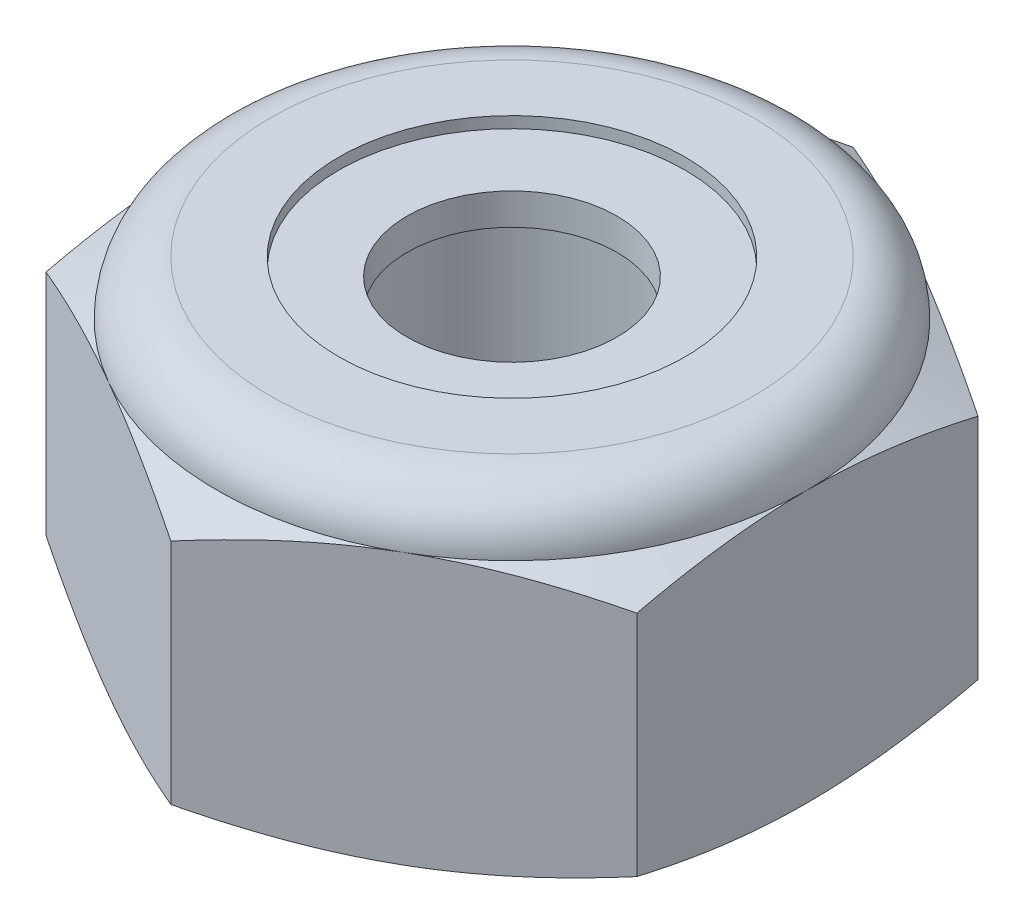
from build123d import *

# Parameters (mm, degrees)
EXTRUDE1_DEPTH = 4.365625
SKETCH2_W      = 1.7526
SKETCH2_H      = 4.365625


with BuildPart() as part:
    # Sketch1 → Extrude1 (new body)
    with BuildSketch(Plane(origin=(0, 0, 0), x_dir=(1, 0, 0), z_dir=(0, 1, 0))):
        Polygon((0, 4.582717762), (-3.96875, 2.291358881), (-3.96875, -2.291358881), (0, -4.582717762), (3.96875, -2.291358881), (3.96875, 2.291358881), align=None)
    extrude(amount=EXTRUDE1_DEPTH)

    # Sketch4 → Cut-Revolve2 (revolve, cut)
    with BuildSketch(Plane(origin=(0, 0, 0), x_dir=(0, 0, -1), z_dir=(1, 0, 0))):
        Polygon((0, 4.365625), (1.7526, 4.365625), (1.410275607, 4.205996514), (1.410275607, 0.159628486), (1.7526, 0), (0, 0), align=None)
    revolve(axis=Axis((0, 4.365625, 0), (0, 1, 0)), mode=Mode.SUBTRACT)


with BuildPart() as body_2:
    # Sketch2 → Revolve1 (revolve)
    with BuildSketch(Plane(origin=(0, 0, 0), x_dir=(0, 0, -1), z_dir=(1, 0, 0))):
        with Locations((0.8763, 2.1828125)):
            Rectangle(SKETCH2_W, SKETCH2_H)
    revolve(axis=Axis((0, -1.7526, 0), (0, 1, 0)))


with BuildPart() as part_1:
    add(part.part)

    # Combine1: cut body 2
    add(body_2.part, mode=Mode.SUBTRACT)

    # Sketch5 → Cut-Revolve3 (revolve, cut)
    with BuildSketch(Plane(origin=(0, 0, 0), x_dir=(0, 0, -1), z_dir=(1, 0, 0))):
        with BuildLine():
            Line((0, 0), (3.96875, 0))
            Line((3.96875, 0), (4.582717762, 0.286297869))
            Line((4.582717762, 0.286297869), (4.582717762, 3.351722964))
            Line((4.582717762, 3.351722964), (3.96875, 3.638020833))
            ThreePointArc((3.96875, 3.638020833), (3.755639674, 4.152514674), (3.241145833, 4.365625))
            Line((3.241145833, 4.365625), (3.241145833, 5.635625))
            Line((3.241145833, 5.635625), (5.852717762, 5.635625))
            Line((5.852717762, 5.635625), (5.852717762, -1.27))
            Line((5.852717762, -1.27), (0, -1.27))
            Line((0, -1.27), (0, 0))
        make_face()
    revolve(axis=Axis((0, 0, 0), (0, 1, 0)), mode=Mode.SUBTRACT)

    # Sketch6 → Cut-Revolve4 (revolve, cut)
    with BuildSketch(Plane(origin=(0, 0, 0), x_dir=(0, 0, -1), z_dir=(1, 0, 0))):
        with BuildLine():
            Line((0, 3.638020833), (3.81635, 3.638020833))
            ThreePointArc((3.81635, 3.638020833), (3.6478766, 4.0447516), (3.241145833, 4.213225))
            Line((3.241145833, 4.213225), (2.32571072, 4.213225))
            Line((2.32571072, 4.213225), (2.32571072, 5.635625))
            Line((2.32571072, 5.635625), (0, 5.635625))
            Line((0, 5.635625), (0, 3.638020833))
        make_face()
    revolve(axis=Axis((0, 5.635625, 0), (0, 1, 0)), mode=Mode.SUBTRACT)


with BuildPart() as body_2_2:
    # Sketch7 → Revolve2 (revolve)
    with BuildSketch(Plane(origin=(0, 0, 0), x_dir=(0, 0, -1), z_dir=(1, 0, 0))):
        with BuildLine():
            Line((1.410275607, 3.714220833), (3.734297654, 3.714220833))
            ThreePointArc((3.734297654, 3.714220833), (3.565938876, 4.016854092), (3.241145833, 4.137025))
            Line((3.241145833, 4.137025), (1.410275607, 4.137025))
            Line((1.410275607, 4.137025), (1.410275607, 3.714220833))
        make_face()
    revolve(axis=Axis((0, 3.714220833, 0), (0, 1, 0)))


solid = Compound([part_1.part, body_2_2.part])
